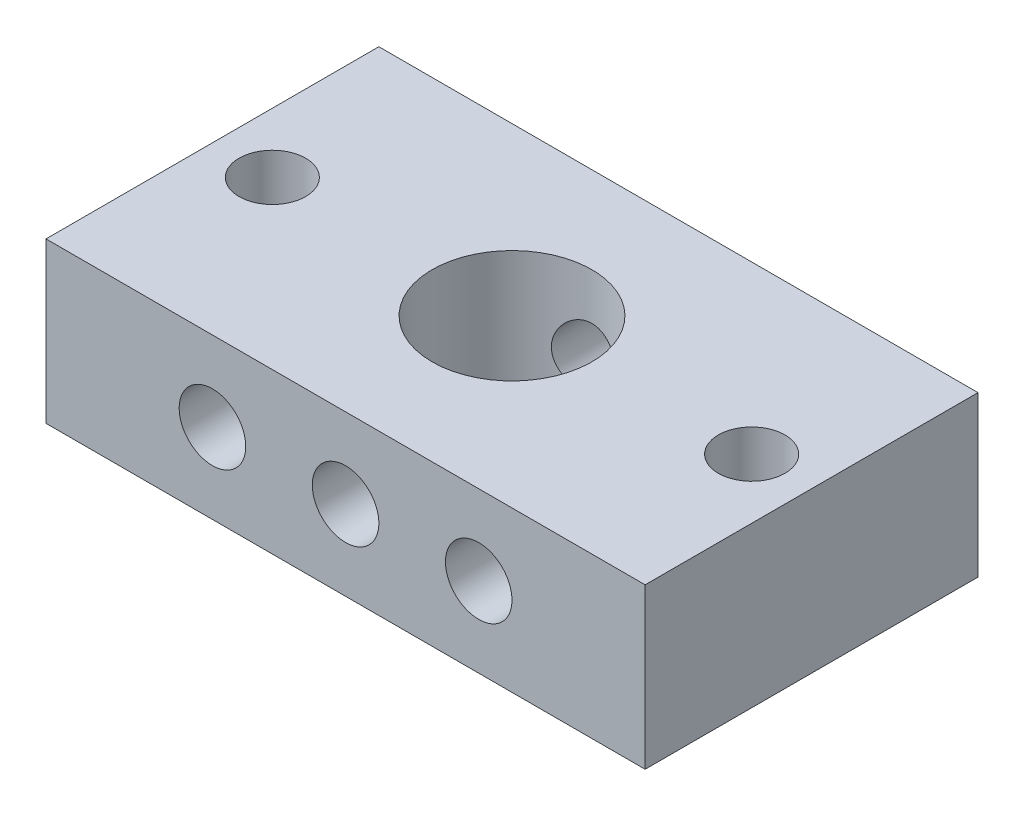
from build123d import *

# Parameters (mm, degrees)
SKETCH1_W           = 45
SKETCH1_H           = 25
BOSS_EXTRUDE1_DEPTH = 12
SKETCH2_R           = 2.5
CUT_EXTRUDE1_DEPTH  = 12
SKETCH3_R           = 2.5
CUT_EXTRUDE2_DEPTH  = 72
SKETCH4_R           = 2.5
CUT_EXTRUDE3_DEPTH  = 72
SKETCH5_R           = 6
CUT_EXTRUDE4_DEPTH  = 72
SKETCH6_R           = 2.5
CUT_EXTRUDE5_DEPTH  = 72
SKETCH7_R           = 2.5
BOSS_EXTRUDE2_DEPTH = 12


with BuildPart() as part:
    # Sketch1 → Boss-Extrude1 (new body)
    with BuildSketch(Plane(origin=(0, 0, 0), x_dir=(1, 0, 0), z_dir=(0, 1, 0))):
        Rectangle(SKETCH1_W, SKETCH1_H)
    extrude(amount=BOSS_EXTRUDE1_DEPTH)

    # Sketch2 → Cut-Extrude1 (cut)
    with BuildSketch(Plane(origin=(0, 12, 0), x_dir=(1, 0, 0), z_dir=(0, 1, 0))):
        with Locations((-18, -7.5)):
            Circle(SKETCH2_R)
        with Locations((-18, 7.5)):
            Circle(SKETCH2_R)
        with Locations((18, -7.5)):
            Circle(SKETCH2_R)
        with Locations((18, 7.5)):
            Circle(SKETCH2_R)
    extrude(amount=-CUT_EXTRUDE1_DEPTH, mode=Mode.SUBTRACT)

    # Sketch3 → Cut-Extrude2 (cut)
    with BuildSketch(Plane(origin=(0, 0, -12.5), x_dir=(-1, 0, 0), z_dir=(0, 0, -1))):
        with Locations((0, 6)):
            Circle(SKETCH3_R)
    extrude(amount=-CUT_EXTRUDE2_DEPTH, mode=Mode.SUBTRACT)

    # Sketch4 → Cut-Extrude3 (cut)
    with BuildSketch(Plane(origin=(0, 0, -12.5), x_dir=(-1, 0, 0), z_dir=(0, 0, -1))):
        with Locations((10, 6)):
            Circle(SKETCH4_R)
        with Locations((-10, 6)):
            Circle(SKETCH4_R)
    extrude(amount=-CUT_EXTRUDE3_DEPTH, mode=Mode.SUBTRACT)

    # Sketch5 → Cut-Extrude4 (cut)
    with BuildSketch(Plane(origin=(0, 12, 0), x_dir=(1, 0, 0), z_dir=(0, 1, 0))):
        Circle(SKETCH5_R)
    extrude(amount=-CUT_EXTRUDE4_DEPTH, mode=Mode.SUBTRACT)

    # Sketch6 → Cut-Extrude5 (cut)
    with BuildSketch(Plane(origin=(0, 12, 0), x_dir=(1, 0, 0), z_dir=(0, 1, 0))):
        with Locations((-18, 0)):
            Circle(SKETCH6_R)
        with Locations((18, 0)):
            Circle(SKETCH6_R)
    extrude(amount=-CUT_EXTRUDE5_DEPTH, mode=Mode.SUBTRACT)

    # Sketch7 → Boss-Extrude2 (add)
    with BuildSketch(Plane(origin=(0, 12, 0), x_dir=(1, 0, 0), z_dir=(0, 1, 0))):
        with Locations((18, -7.5)):
            Circle(SKETCH7_R)
        with Locations((18, 7.5)):
            Circle(SKETCH7_R)
        with Locations((-18, -7.5)):
            Circle(SKETCH7_R)
        with Locations((-18, 7.5)):
            Circle(SKETCH7_R)
    extrude(amount=-BOSS_EXTRUDE2_DEPTH)


solid = part.part
